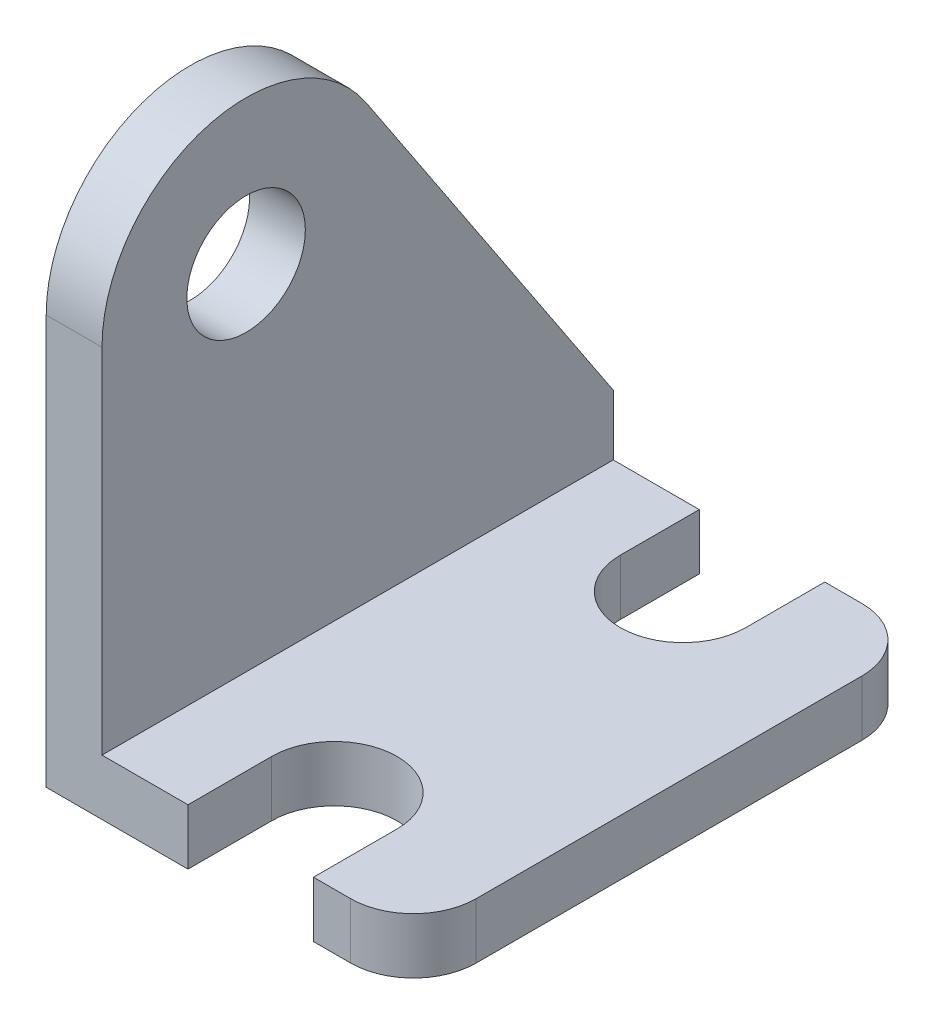
from build123d import *

# Parameters (mm, degrees)
BASE_EXTRUDE_DEPTH = 3.048
SKETCH4_R          = 3.2385
REARRIB_DEPTH      = 3.048


with BuildPart() as part:
    # Sketch2 → Base-Extrude (new body)
    with BuildSketch(Plane(origin=(0, 0, 0), x_dir=(1, 0, 0), z_dir=(0, 1, 0))):
        with BuildLine():
            Line((0, 13.97), (7.747, 13.97))
            Line((7.747, 13.97), (7.747, 9.652))
            ThreePointArc((7.747, 9.652), (11.176, 6.223), (14.605, 9.652))
            Line((14.605, 9.652), (14.605, 13.97))
            Line((14.605, 13.97), (16.637, 13.97))
            ThreePointArc((16.637, 13.97), (19.061669153, 12.965669153), (20.066, 10.541))
            Line((20.066, 10.541), (20.066, -10.541))
            ThreePointArc((20.066, -10.541), (19.061669153, -12.965669153), (16.637, -13.97))
            Line((16.637, -13.97), (14.605, -13.97))
            Line((14.605, -13.97), (14.605, -9.398))
            ThreePointArc((14.605, -9.398), (11.176, -5.969), (7.747, -9.398))
            Line((7.747, -9.398), (7.747, -13.97))
            Line((7.747, -13.97), (0, -13.97))
            Line((0, -13.97), (0, 13.97))
        make_face()
    extrude(amount=BASE_EXTRUDE_DEPTH)

    # Sketch4 → RearRib (add)
    with BuildSketch(Plane.ZY):
        with BuildLine():
            Line((13.97, 22.352), (13.97, 0))
            Line((13.97, 0), (-13.97, 0))
            Line((-13.97, 0), (-13.97, 6.35))
            Line((-13.97, 6.35), (-0.465269586, 26.70511583))
            ThreePointArc((-0.465269586, 26.70511583), (8.369371866, 29.890677361), (13.97, 22.352))
        make_face()
        with Locations((6.096, 22.352)):
            Circle(SKETCH4_R, mode=Mode.SUBTRACT)
    extrude(amount=-REARRIB_DEPTH)


solid = part.part
